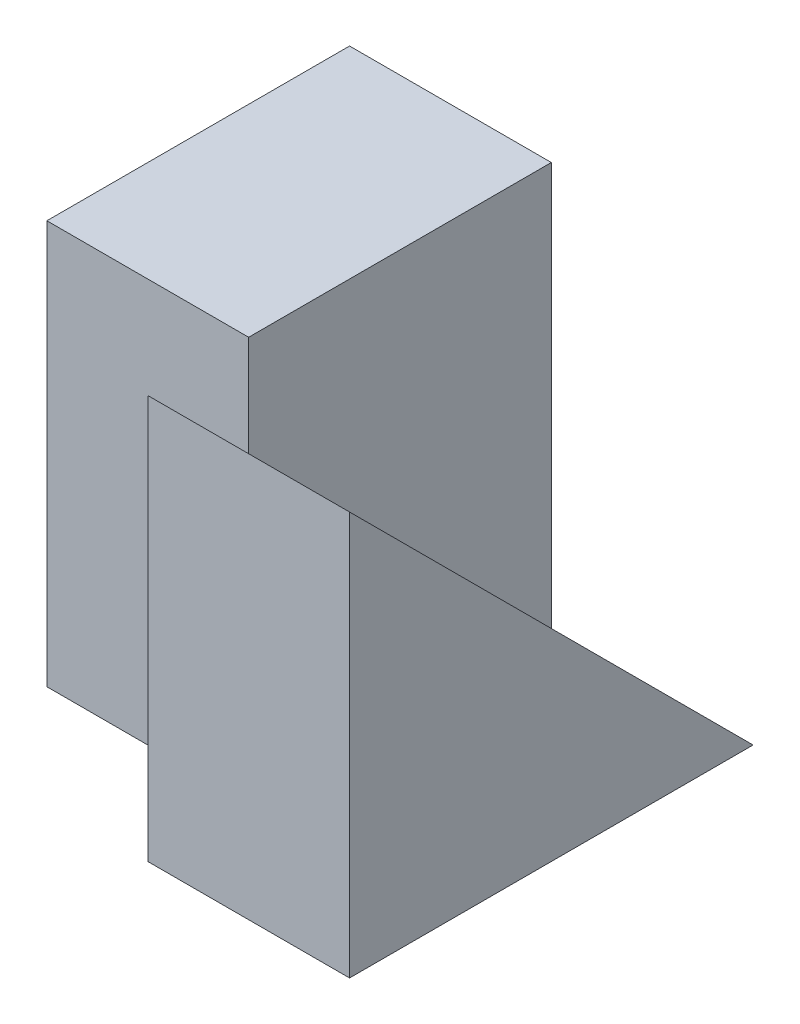
from build123d import *

# Parameters (mm, degrees)
SKETCH1_W           = 4
SKETCH1_H           = 4
BOSS_EXTRUDE1_DEPTH = 2
SKETCH2_W           = 3
SKETCH2_H           = 4
BOSS_EXTRUDE2_DEPTH = 2
CUT_EXTRUDE1_DEPTH  = 2


with BuildPart() as part:
    # Sketch1 → Boss-Extrude1 (new body)
    with BuildSketch(Plane(origin=(0, 0, 0), x_dir=(0, 0, -1), z_dir=(1, 0, 0))):
        with Locations((2, 2)):
            Rectangle(SKETCH1_W, SKETCH1_H)
    extrude(amount=BOSS_EXTRUDE1_DEPTH)

    # Sketch2 → Boss-Extrude2 (add)
    with BuildSketch(Plane.ZY):
        with Locations((-2.5, 2)):
            Rectangle(SKETCH2_W, SKETCH2_H)
    extrude(amount=BOSS_EXTRUDE2_DEPTH)

    # Sketch3 → Cut-Extrude1 (cut)
    with BuildSketch(Plane(origin=(2, 0, 0), x_dir=(0, 0, -1), z_dir=(1, 0, 0))):
        Polygon((4, 0), (0, 4), (4, 4), align=None)
    extrude(amount=-CUT_EXTRUDE1_DEPTH, mode=Mode.SUBTRACT)


solid = part.part
